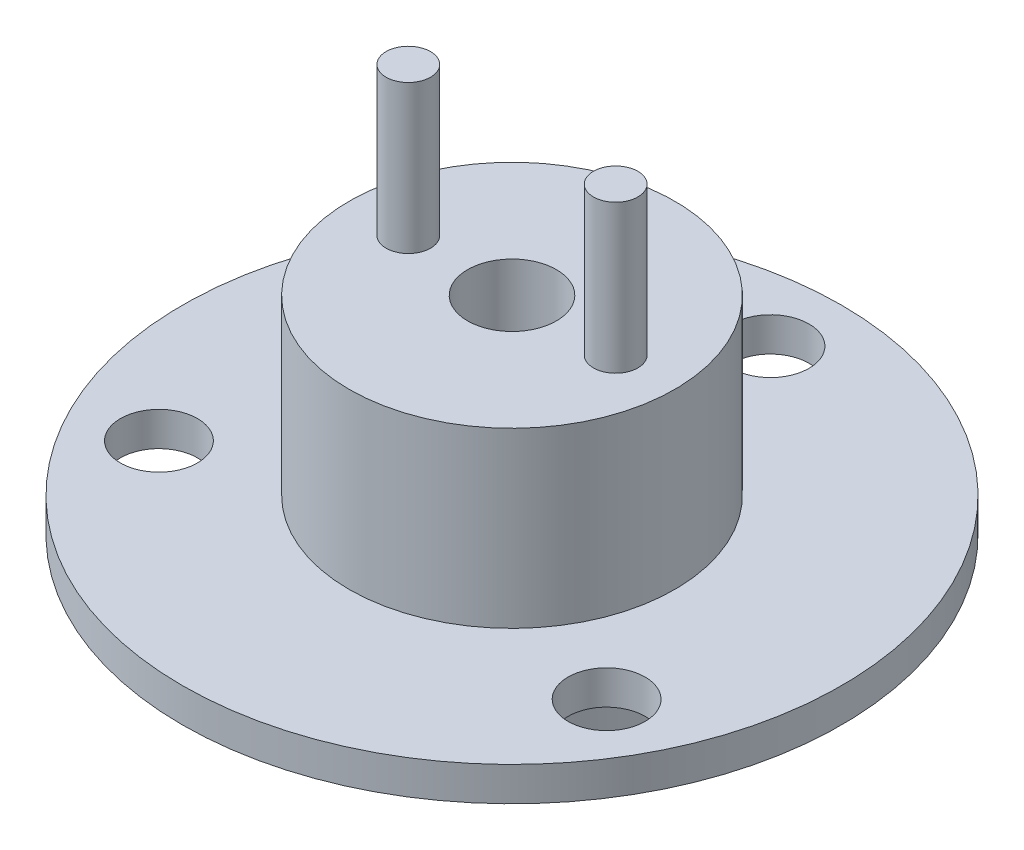
from build123d import *

# Parameters (mm, degrees)
CROQUIS1_R              = 11
SALIENTE_EXTRUIR1_DEPTH = 19
CROQUIS2_R              = 22.25
SALIENTE_EXTRUIR2_DEPTH = 2.3
CROQUIS3_R              = 2.6
CORTAR_EXTRUIR1_DEPTH   = 2.3
CROQUIS4_R              = 3
CORTAR_EXTRUIR2_DEPTH   = 27.3
CROQUIS5_R              = 1.5
SALIENTE_EXTRUIR3_DEPTH = 10


with BuildPart() as part:
    # Croquis1 → Saliente-Extruir1 (new body)
    with BuildSketch(Plane(origin=(0, 0, 0), x_dir=(1, 0, 0), z_dir=(0, 1, 0))):
        Circle(CROQUIS1_R)
    extrude(amount=SALIENTE_EXTRUIR1_DEPTH)

    # Croquis2 → Saliente-Extruir2 (add)
    with BuildSketch(Plane(origin=(0, 5, 0), x_dir=(1, 0, 0), z_dir=(0, 1, 0))):
        Circle(CROQUIS2_R)
    extrude(amount=SALIENTE_EXTRUIR2_DEPTH)

    # Croquis3 → Cortar-Extruir1 (cut)
    with BuildSketch(Plane.XZ.offset(-5)):
        with Locations((15.112143296, 8.725)):
            Circle(CROQUIS3_R)
        with Locations((-15.112143296, 8.725)):
            Circle(CROQUIS3_R)
        with Locations((0, -17.45)):
            Circle(CROQUIS3_R)
    extrude(amount=-CORTAR_EXTRUIR1_DEPTH, mode=Mode.SUBTRACT)

    # Croquis4 → Cortar-Extruir2 (cut)
    with BuildSketch(Plane(origin=(0, 19, 0), x_dir=(1, 0, 0), z_dir=(0, 1, 0))):
        Circle(CROQUIS4_R)
    extrude(amount=-CORTAR_EXTRUIR2_DEPTH, mode=Mode.SUBTRACT)

    # Croquis5 → Saliente-Extruir3 (add)
    with BuildSketch(Plane(origin=(0, 19, 0), x_dir=(1, 0, 0), z_dir=(0, 1, 0))):
        with Locations((-7, 0)):
            Circle(CROQUIS5_R)
        with Locations((7, 0)):
            Circle(CROQUIS5_R)
    extrude(amount=SALIENTE_EXTRUIR3_DEPTH)


solid = part.part
